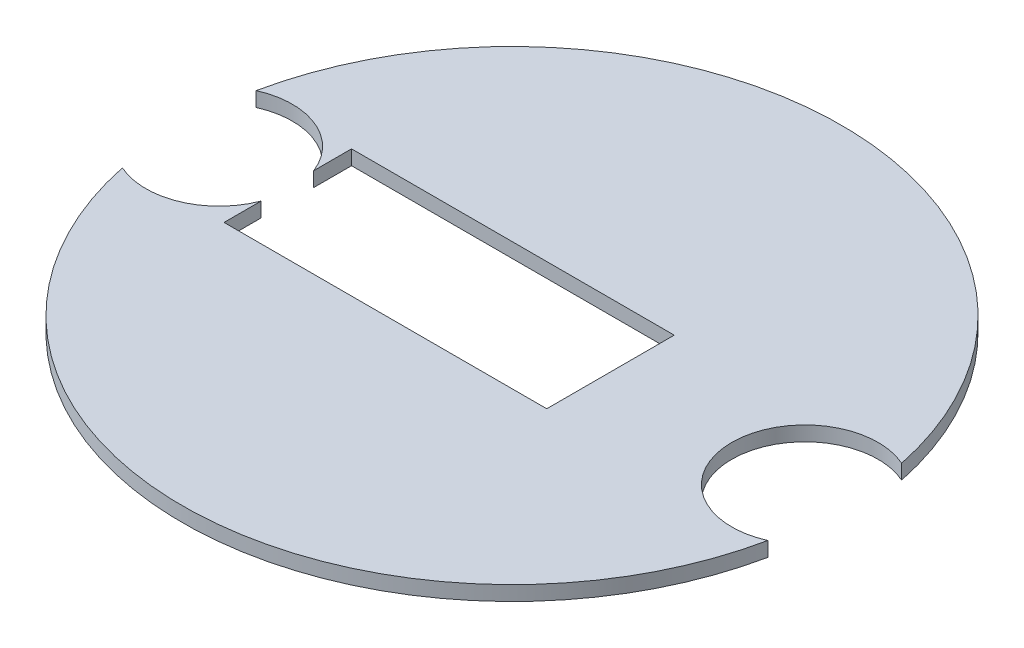
from build123d import *

# Parameters (mm, degrees)
SKETCH1_R           = 57.15
BOSS_EXTRUDE1_DEPTH = 2.54
SKETCH3_W           = 55.958888442
SKETCH3_H           = 22.106904705
CUT_EXTRUDE1_DEPTH  = 2.54
SKETCH4_R           = 12.7
CUT_EXTRUDE2_DEPTH  = 2.54
SKETCH5_R           = 12.7
CUT_EXTRUDE3_DEPTH  = 2.54


with BuildPart() as part:
    # Sketch1 → Boss-Extrude1 (new body)
    with BuildSketch(Plane(origin=(0, 0, 0), x_dir=(1, 0, 0), z_dir=(0, 1, 0))):
        Circle(SKETCH1_R)
    extrude(amount=BOSS_EXTRUDE1_DEPTH)

    # Sketch3 → Cut-Extrude1 (cut)
    with BuildSketch(Plane(origin=(0, 2.54, 0), x_dir=(1, 0, 0), z_dir=(0, 1, 0))):
        with Locations((-10.970545038, 0.068604303)):
            Rectangle(SKETCH3_W, SKETCH3_H)
    extrude(amount=-CUT_EXTRUDE1_DEPTH, mode=Mode.SUBTRACT)

    # Sketch4 → Cut-Extrude2 (cut)
    with BuildSketch(Plane(origin=(0, 0, 0), x_dir=(-1, 0, 0), z_dir=(0, -1, 0))):
        with Locations((50.8, 0)):
            Circle(SKETCH4_R)
    extrude(amount=-CUT_EXTRUDE2_DEPTH, mode=Mode.SUBTRACT)

    # Sketch5 → Cut-Extrude3 (cut)
    with BuildSketch(Plane.XZ):
        with Locations((50.8, 0)):
            Circle(SKETCH5_R)
    extrude(amount=-CUT_EXTRUDE3_DEPTH, mode=Mode.SUBTRACT)


solid = part.part
